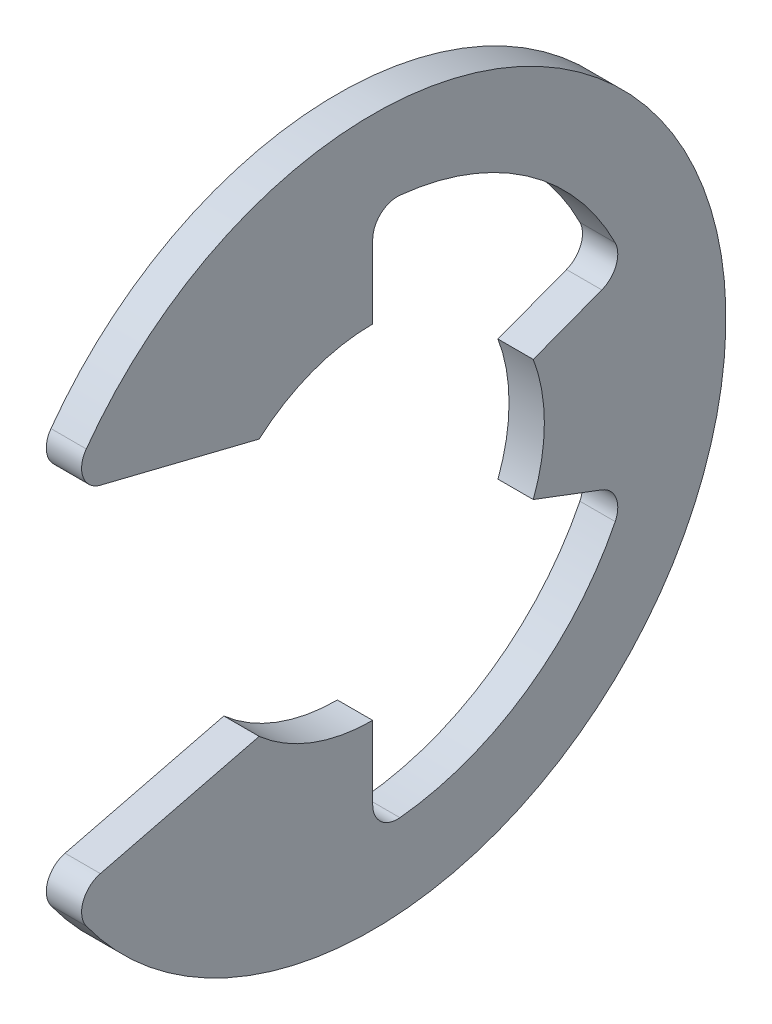
from build123d import *

# Parameters (mm, degrees)
EXTRUDE1_DEPTH = 0.3175
FILLET1_R      = 0.4445


with BuildPart() as part:
    # Sketch1 → Extrude1 (new body, symmetric)
    with BuildSketch(Plane(origin=(0, 0, 0), x_dir=(0, 0, -1), z_dir=(1, 0, 0))):
        with BuildLine():
            Line((-5.500228654, -3.173323929), (-2.04126328, -2.314575))
            ThreePointArc((-2.04126328, -2.314575), (-1.091101119, -2.886782215), (0, -3.0861))
            Line((0, -3.0861), (0, -4.870245161))
            ThreePointArc((0, -4.870245161), (2.768867391, -4.006577255), (4.555697196, -1.72189169))
            Line((4.555697196, -1.72189169), (2.886782215, -1.091101119))
            ThreePointArc((2.886782215, -1.091101119), (3.0861, 0), (2.886782215, 1.091101119))
            Line((2.886782215, 1.091101119), (4.555697196, 1.72189169))
            ThreePointArc((4.555697196, 1.72189169), (2.768867391, 4.006577255), (0, 4.870245161))
            Line((0, 4.870245161), (0, 3.0861))
            ThreePointArc((0, 3.0861), (-1.091101119, 2.886782215), (-2.04126328, 2.314575))
            Line((-2.04126328, 2.314575), (-5.500228654, 3.173323929))
            ThreePointArc((-5.500228654, 3.173323929), (6.35, 0), (-5.500228654, -3.173323929))
        make_face()
    extrude(amount=EXTRUDE1_DEPTH, both=True)

    # Fillet1
    fillet1_edges = [part.edges().sort_by_distance(p)[0] for p in [
        (0, -3.173323929, 5.500228654),
        (0, -4.870245161, 0),
        (0, -1.72189169, -4.555697196),
        (0, 1.72189169, -4.555697196),
        (0, 4.870245161, 0),
        (0, 3.173323929, 5.500228654),
    ]]
    fillet(fillet1_edges, radius=FILLET1_R)


solid = part.part
